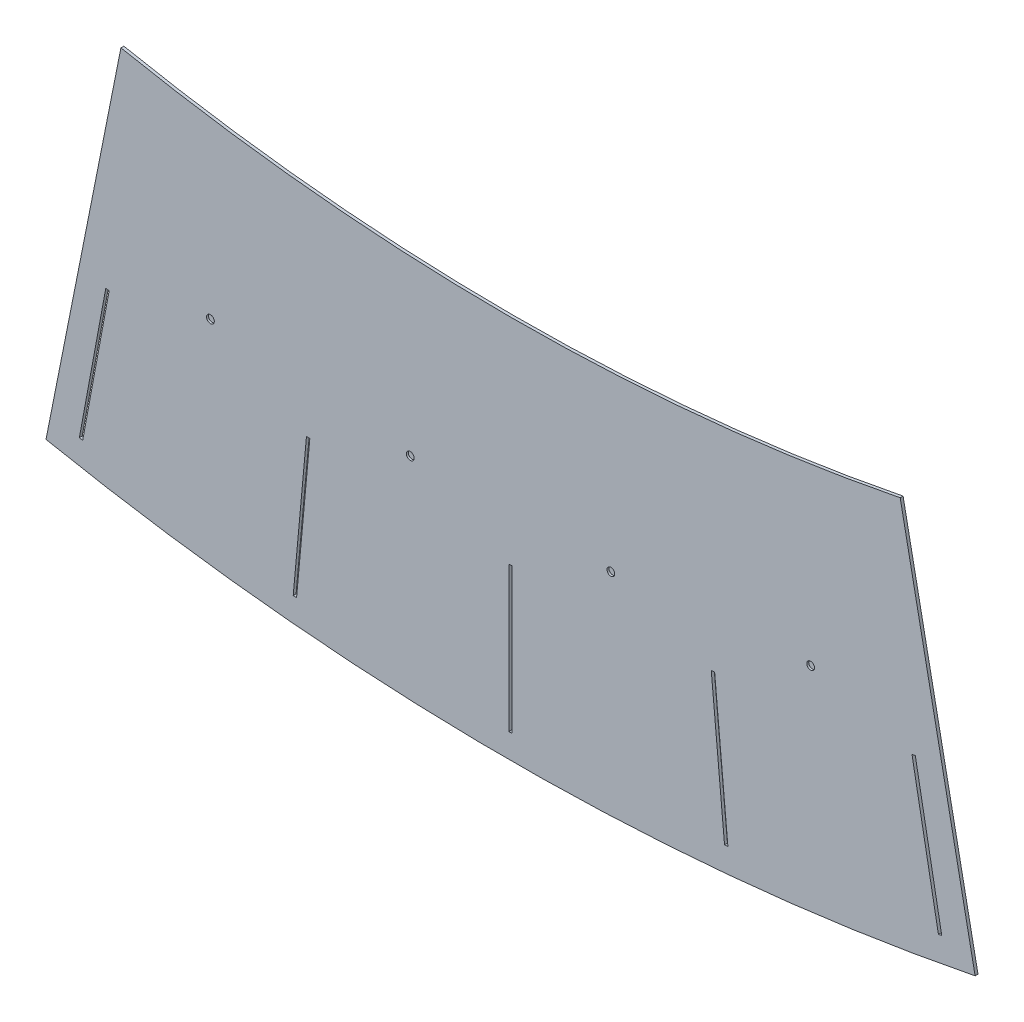
from build123d import *

# Parameters (mm, degrees)
SKETCH1_W           = 3.5
SKETCH1_H           = 150
BOSS_EXTRUDE1_DEPTH = 3
SKETCH3_R           = 4
CUT_EXTRUDE1_DEPTH  = 2


with BuildPart() as part:
    # Sketch1 → Boss-Extrude1 (new body)
    with BuildSketch(Plane.XY):
        with BuildLine():
            Line((-480.312372804, -2414.693360353), (-402.861514963, -2025.321604033))
            ThreePointArc((-402.861514963, -2025.321604033), (0, -2065), (402.861514963, -2025.321604033))
            Line((402.861514963, -2025.321604033), (480.312372804, -2414.693360353))
            ThreePointArc((480.312372804, -2414.693360353), (0, -2462), (-480.312372804, -2414.693360353))
        make_face()
        Polygon((-207.52154326, -2277.565997196), (-221.246786059, -2426.936736332), (-224.732103306, -2426.616480667), (-211.006860506, -2277.245741531), align=None, mode=Mode.SUBTRACT)
        with Locations((0, -2362)):
            Rectangle(SKETCH1_W, SKETCH1_H, mode=Mode.SUBTRACT)
        Polygon((-415.051950712, -2249.022885768), (-442.387279536, -2396.511121903), (-445.828671713, -2395.873297564), (-418.493342889, -2248.385061429), align=None, mode=Mode.SUBTRACT)
        Polygon((211.006860506, -2277.245741531), (224.732103306, -2426.616480667), (221.246786059, -2426.936736332), (207.52154326, -2277.565997196), align=None, mode=Mode.SUBTRACT)
        Polygon((418.493342889, -2248.385061429), (445.828671713, -2395.873297564), (442.387279536, -2396.511121903), (415.051950712, -2249.022885768), align=None, mode=Mode.SUBTRACT)
    extrude(amount=BOSS_EXTRUDE1_DEPTH)

    # Sketch3 → Cut-Extrude1 (cut)
    with BuildSketch(Plane.XY.offset(3)):
        with Locations((310.304616094, -2222)):
            Circle(SKETCH3_R)
        with Locations((103.730524899, -2241.163299042)):
            Circle(SKETCH3_R)
        with Locations((-103.730524899, -2241.163299042)):
            Circle(SKETCH3_R)
        with Locations((-310.304616094, -2222)):
            Circle(SKETCH3_R)
    extrude(amount=-CUT_EXTRUDE1_DEPTH, mode=Mode.SUBTRACT)


solid = part.part
